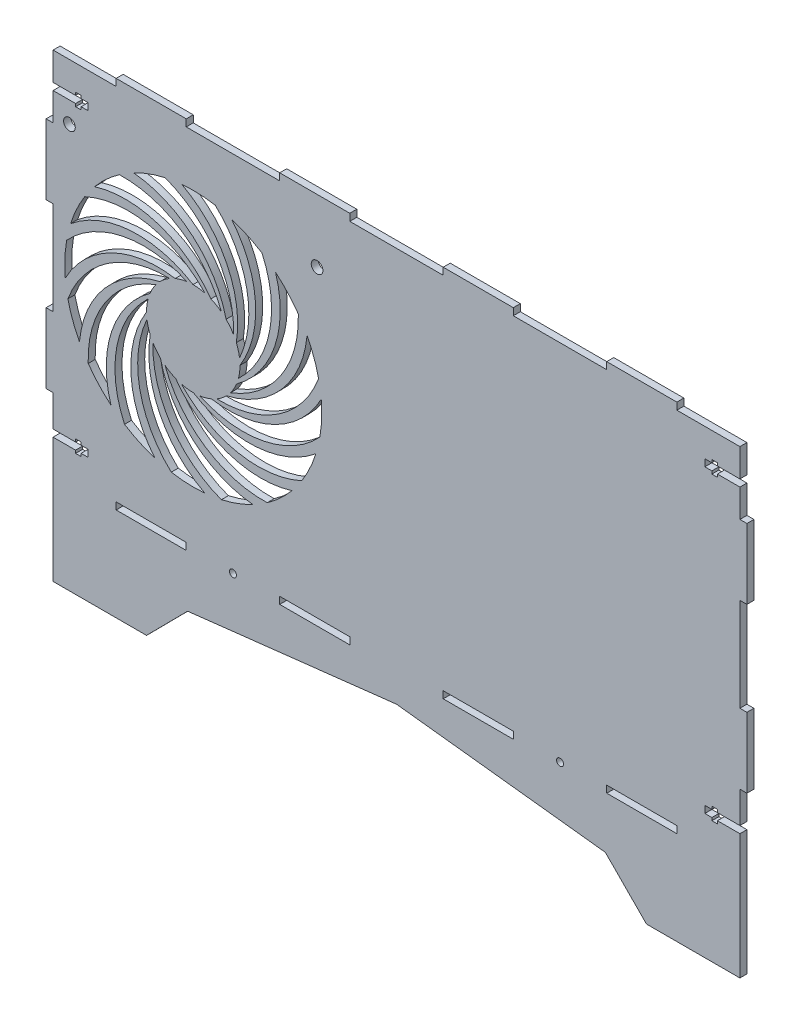
from build123d import *

# Parameters (mm, degrees)
MODEL_R             = 1.5
MODEL_R_2           = 2.5
MODEL_W             = 30
MODEL_H             = 3
BOSS_EXTRUDE1_DEPTH = 3


with BuildPart() as part:
    # Model → Boss-Extrude1 (new body)
    with BuildSketch(Plane.XY):
        Polygon((293.898614086, 53.203891691), (284.268614086, 53.203891691), (284.268614086, 52.003891691), (281.898614086, 52.003891691), (281.898614086, 53.203891691), (278.898614086, 53.203891691), (278.898614086, 56.203891691), (281.898614086, 56.203891691), (281.898614086, 57.403891691), (284.268614086, 57.403891691), (284.268614086, 56.203891691), (293.898614086, 56.203891691), (293.898614086, 69.703891691), (296.898614086, 69.703891691), (296.898614086, 99.703891691), (293.898614086, 99.703891691), (293.898614086, 139.703891691), (296.898614086, 139.703891691), (296.898614086, 169.703891691), (293.898614086, 169.703891691), (293.898614086, 181.703891691), (284.268614086, 181.703891691), (284.268614086, 180.503891691), (281.898614086, 180.503891691), (281.898614086, 181.703891691), (278.898614086, 181.703891691), (278.898614086, 184.703891691), (281.898614086, 184.703891691), (281.898614086, 185.903891691), (284.268614086, 185.903891691), (284.268614086, 184.703891691), (293.898614086, 184.703891691), (293.898614086, 196.703891691), (266.898614086, 196.703891691), (266.898614086, 199.703891691), (236.898614086, 199.703891691), (236.898614086, 196.703891691), (196.898614086, 196.703891691), (196.898614086, 199.703891691), (166.898614086, 199.703891691), (166.898614086, 196.703891691), (126.898614086, 196.703891691), (126.898614086, 199.703891691), (96.898614086, 199.703891691), (96.898614086, 196.703891691), (56.898614086, 196.703891691), (56.898614086, 199.703891691), (26.898614086, 199.703891691), (26.898614086, 196.703891691), (-0.101385914, 196.703891691), (-0.101385914, 184.703891691), (9.528614086, 184.703891691), (9.528614086, 185.903891691), (11.898614086, 185.903891691), (11.898614086, 184.703891691), (14.898614086, 184.703891691), (14.898614086, 181.703891691), (11.898614086, 181.703891691), (11.898614086, 180.503891691), (9.528614086, 180.503891691), (9.528614086, 181.703891691), (-0.101385914, 181.703891691), (-0.101385914, 169.703891691), (-3.101385914, 169.703891691), (-3.101385914, 139.703891691), (-0.101385914, 139.703891691), (-0.101385914, 99.703891691), (-3.101385914, 99.703891691), (-3.101385914, 69.703891691), (-0.101385914, 69.703891691), (-0.101385914, 56.203891691), (9.528614086, 56.203891691), (9.528614086, 57.403891691), (11.898614086, 57.403891691), (11.898614086, 56.203891691), (14.898614086, 56.203891691), (14.898614086, 53.203891691), (11.898614086, 53.203891691), (11.898614086, 52.003891691), (9.528614086, 52.003891691), (9.528614086, 53.203891691), (-0.101385914, 53.203891691), (-0.101385914, -0.296108309), (39.898614086, -0.296108309), (57.481710262, 17.475631303), (146.898614086, 27.703891691), (236.31551791, 17.475631303), (253.898614086, -0.296108309), (293.898614086, -0.296108309), align=None)
        with Locations((76.898614086, 41.203891691)):
            Circle(MODEL_R, mode=Mode.SUBTRACT)
        with Locations((216.898614086, 41.203891691)):
            Circle(MODEL_R, mode=Mode.SUBTRACT)
        with Locations((6.898614086, 172.703891691)):
            Circle(MODEL_R_2, mode=Mode.SUBTRACT)
        with Locations((112.898614086, 172.703891691)):
            Circle(MODEL_R_2, mode=Mode.SUBTRACT)
        with Locations((181.898614086, 41.203891691)):
            Rectangle(MODEL_W, MODEL_H, mode=Mode.SUBTRACT)
        with Locations((111.898614086, 41.203891691)):
            Rectangle(MODEL_W, MODEL_H, mode=Mode.SUBTRACT)
        with Locations((251.898614086, 41.203891691)):
            Rectangle(MODEL_W, MODEL_H, mode=Mode.SUBTRACT)
        with Locations((41.898614086, 41.203891691)):
            Rectangle(MODEL_W, MODEL_H, mode=Mode.SUBTRACT)
        with BuildLine():
            ThreePointArc((6.234247088, 107.656663186), (8.26583205, 100.755123414), (11.180868228, 94.177802321))
            ThreePointArc((11.180868228, 94.177802321), (22.055838559, 119.523362015), (45.674995189, 133.764071827))
            ThreePointArc((45.674995189, 133.764071827), (47.631901996, 135.500339851), (49.798695647, 136.966326268))
            ThreePointArc((49.798695647, 136.966326268), (23.298575347, 129.323944441), (6.234247088, 107.656663186))
        make_face(mode=Mode.SUBTRACT)
        with BuildLine():
            ThreePointArc((71.94584259, 66.039524692), (78.847382363, 68.071109654), (85.424703456, 70.986145833))
            ThreePointArc((85.424703456, 70.986145833), (60.079143762, 81.861116163), (45.83843395, 105.480272794))
            ThreePointArc((45.83843395, 105.480272794), (44.102165926, 107.4371796), (42.636179509, 109.603973252))
            ThreePointArc((42.636179509, 109.603973252), (50.278561336, 83.103852952), (71.94584259, 66.039524692))
        make_face(mode=Mode.SUBTRACT)
        with BuildLine():
            ThreePointArc((113.562981085, 131.751120195), (111.531396123, 138.652659967), (108.616359944, 145.229981061))
            ThreePointArc((108.616359944, 145.229981061), (97.741389614, 119.884421366), (74.122232983, 105.643711554))
            ThreePointArc((74.122232983, 105.643711554), (72.165326177, 103.90744353), (69.998532525, 102.441457114))
            ThreePointArc((69.998532525, 102.441457114), (96.498652825, 110.083838941), (113.562981085, 131.751120195))
        make_face(mode=Mode.SUBTRACT)
        with BuildLine():
            ThreePointArc((47.851385582, 173.368258689), (40.94984581, 171.336673727), (34.372524716, 168.421637549))
            ThreePointArc((34.372524716, 168.421637549), (59.718084411, 157.546667218), (73.958794223, 133.927510588))
            ThreePointArc((73.958794223, 133.927510588), (75.695062247, 131.970603781), (77.161048663, 129.80381013))
            ThreePointArc((77.161048663, 129.80381013), (69.518666836, 156.30393043), (47.851385582, 173.368258689))
        make_face(mode=Mode.SUBTRACT)
        with BuildLine():
            ThreePointArc((79.712095528, 122.428951901), (82.792612373, 149.836483565), (69.304890407, 173.89357674))
            ThreePointArc((69.304890407, 173.89357674), (62.151245162, 174.657741904), (54.959056774, 174.481631454))
            ThreePointArc((54.959056774, 174.481631454), (74.213629643, 154.73514317), (78.331670038, 127.464204073))
            ThreePointArc((78.331670038, 127.464204073), (79.186896715, 124.991816921), (79.712095528, 122.428951901))
        make_face(mode=Mode.SUBTRACT)
        with BuildLine():
            ThreePointArc((114.088299136, 110.29761537), (114.852464299, 117.451260615), (114.676353849, 124.643449003))
            ThreePointArc((114.676353849, 124.643449003), (94.929865566, 105.388876134), (67.658926469, 101.270835739))
            ThreePointArc((67.658926469, 101.270835739), (65.186539317, 100.415609062), (62.623674297, 99.890410249))
            ThreePointArc((62.623674297, 99.890410249), (90.03120596, 96.809893404), (114.088299136, 110.29761537))
        make_face(mode=Mode.SUBTRACT)
        with BuildLine():
            ThreePointArc((50.492337766, 65.514206641), (57.645983011, 64.750041478), (64.838171398, 64.926151927))
            ThreePointArc((64.838171398, 64.926151927), (45.58359853, 84.672640211), (41.465558135, 111.943579308))
            ThreePointArc((41.465558135, 111.943579308), (40.610331458, 114.41596646), (40.085132644, 116.97883148))
            ThreePointArc((40.085132644, 116.97883148), (37.0046158, 89.571299817), (50.492337766, 65.514206641))
        make_face(mode=Mode.SUBTRACT)
        with BuildLine():
            ThreePointArc((5.708929037, 129.110168011), (4.944763873, 121.956522766), (5.120874323, 114.764334379))
            ThreePointArc((5.120874323, 114.764334379), (24.867362607, 134.018907247), (52.138301704, 138.136947642))
            ThreePointArc((52.138301704, 138.136947642), (54.610688856, 138.992174319), (57.173553875, 139.517373132))
            ThreePointArc((57.173553875, 139.517373132), (29.766022212, 142.597889977), (5.708929037, 129.110168011))
        make_face(mode=Mode.SUBTRACT)
        with BuildLine():
            ThreePointArc((14.929478546, 88.037239693), (19.44752324, 82.438502261), (24.657697313, 77.477385975))
            ThreePointArc((24.657697313, 77.477385975), (25.005534039, 105.055300789), (41.377105715, 127.250661042))
            ThreePointArc((41.377105715, 127.250661042), (42.520610854, 129.603639346), (43.961458446, 131.787230223))
            ThreePointArc((43.961458446, 131.787230223), (22.4031526, 114.585433079), (14.929478546, 88.037239693))
        make_face(mode=Mode.SUBTRACT)
        with BuildLine():
            ThreePointArc((91.565266084, 74.73475615), (97.164003515, 79.252800844), (102.125119802, 84.462974917))
            ThreePointArc((102.125119802, 84.462974917), (74.547204988, 84.810811643), (52.351844735, 101.182383319))
            ThreePointArc((52.351844735, 101.182383319), (49.998866431, 102.325888458), (47.815275554, 103.76673605))
            ThreePointArc((47.815275554, 103.76673605), (65.017072698, 82.208430205), (91.565266084, 74.73475615))
        make_face(mode=Mode.SUBTRACT)
        with BuildLine():
            ThreePointArc((104.867749627, 151.370543688), (100.349704933, 156.96928112), (95.13953086, 161.930397407))
            ThreePointArc((95.13953086, 161.930397407), (94.791694134, 134.352482592), (78.420122458, 112.157122339))
            ThreePointArc((78.420122458, 112.157122339), (77.276617319, 109.804144035), (75.835769727, 107.620553158))
            ThreePointArc((75.835769727, 107.620553158), (97.394075572, 124.822350303), (104.867749627, 151.370543688))
        make_face(mode=Mode.SUBTRACT)
        with BuildLine():
            ThreePointArc((28.231962089, 164.673027231), (22.633224657, 160.154982537), (17.67210837, 154.944808464))
            ThreePointArc((17.67210837, 154.944808464), (45.250023185, 154.596971738), (67.445383438, 138.225400062))
            ThreePointArc((67.445383438, 138.225400062), (69.798361742, 137.081894923), (71.981952619, 135.641047331))
            ThreePointArc((71.981952619, 135.641047331), (54.780155474, 157.199353177), (28.231962089, 164.673027231))
        make_face(mode=Mode.SUBTRACT)
        with BuildLine():
            ThreePointArc((79.246719453, 114.639227959), (92.581154205, 138.78162274), (89.326374929, 166.169006473))
            ThreePointArc((89.326374929, 166.169006473), (83.009701852, 169.612584543), (76.297591656, 172.202211042))
            ThreePointArc((76.297591656, 172.202211042), (86.529843523, 146.590428643), (79.898280181, 119.819460346))
            ThreePointArc((79.898280181, 119.819460346), (79.742265001, 117.20799138), (79.246719453, 114.639227959))
        make_face(mode=Mode.SUBTRACT)
        with BuildLine():
            ThreePointArc((106.363728869, 90.276130848), (109.807306939, 96.592803925), (112.396933437, 103.304914121))
            ThreePointArc((112.396933437, 103.304914121), (86.785151039, 93.072662254), (60.014182742, 99.704225596))
            ThreePointArc((60.014182742, 99.704225596), (57.402713775, 99.860240776), (54.833950355, 100.355786324))
            ThreePointArc((54.833950355, 100.355786324), (78.976345135, 87.021351572), (106.363728869, 90.276130848))
        make_face(mode=Mode.SUBTRACT)
        with BuildLine():
            ThreePointArc((30.470853243, 73.238776908), (36.78752632, 69.795198838), (43.499636517, 67.20557234))
            ThreePointArc((43.499636517, 67.20557234), (33.26738465, 92.817354738), (39.898947992, 119.588323035))
            ThreePointArc((39.898947992, 119.588323035), (40.054963171, 122.199792002), (40.550508719, 124.768555422))
            ThreePointArc((40.550508719, 124.768555422), (27.216073967, 100.626160642), (30.470853243, 73.238776908))
        make_face(mode=Mode.SUBTRACT)
        with BuildLine():
            ThreePointArc((13.433499304, 149.131652534), (9.989921234, 142.814979457), (7.400294735, 136.10286926))
            ThreePointArc((7.400294735, 136.10286926), (33.012077134, 146.335121127), (59.783045431, 139.703557785))
            ThreePointArc((59.783045431, 139.703557785), (62.394514397, 139.547542606), (64.963277818, 139.051997057))
            ThreePointArc((64.963277818, 139.051997057), (40.820883037, 152.386431809), (13.433499304, 149.131652534))
        make_face(mode=Mode.SUBTRACT)
    extrude(amount=BOSS_EXTRUDE1_DEPTH)


solid = part.part
